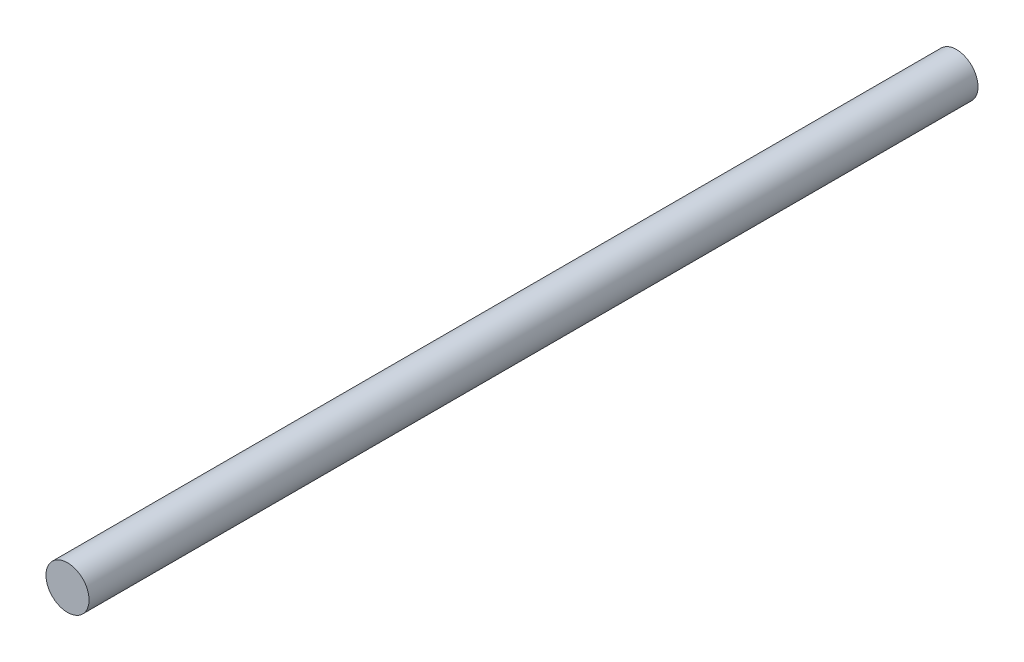
from build123d import *

# Parameters (mm, degrees)
EXTRUDE_3_DEPTH      = 165
EXTRUDE_3_DEPTH_BACK = 165
SKETCH_1_R           = 8


with BuildPart() as part:
    # Эскиз1 → Бобышка-Вытянуть3 (new, two sides: drawn at the far end of the back side and taken through both)
    with BuildSketch(Plane.XY.offset(-EXTRUDE_3_DEPTH_BACK)):
        Circle(SKETCH_1_R)
    extrude(amount=EXTRUDE_3_DEPTH + EXTRUDE_3_DEPTH_BACK)


solid = part.part
